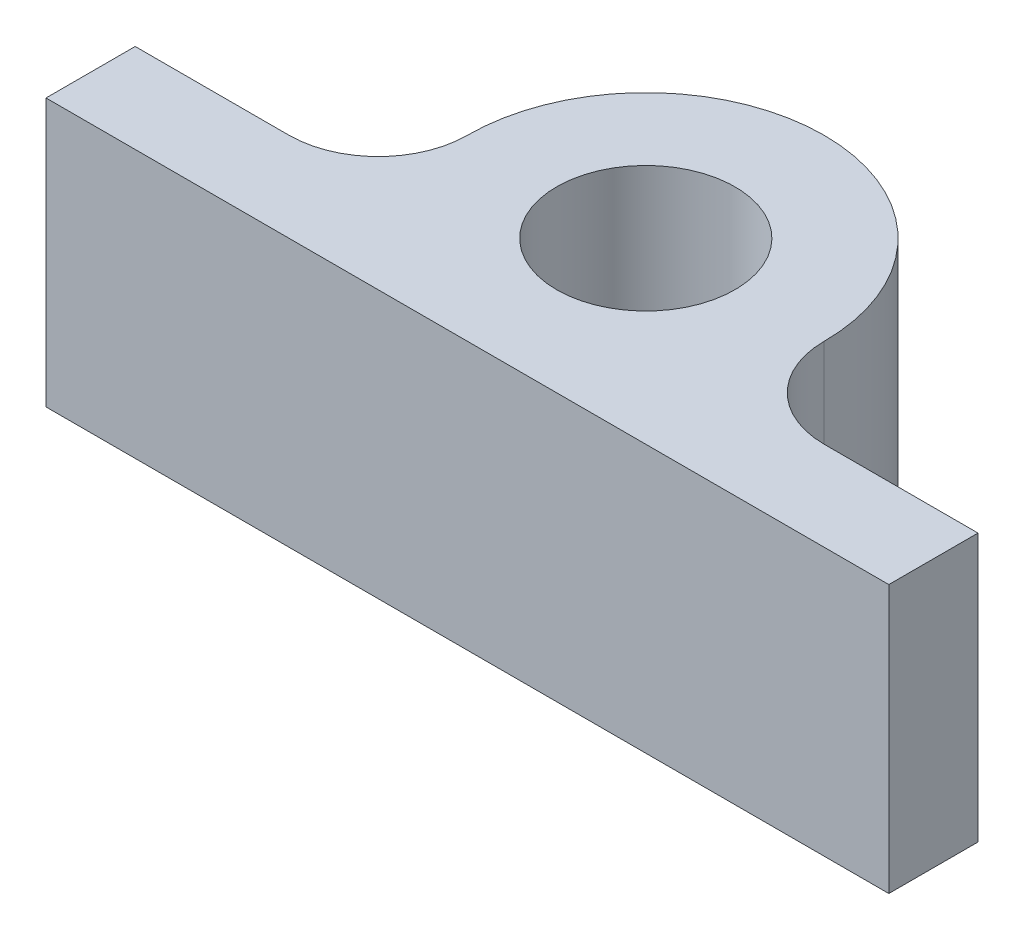
from build123d import *

# Parameters (mm, degrees)
SKETCH1_R           = 12.7
BOSS_EXTRUDE1_DEPTH = 38.1


with BuildPart() as part:
    # Sketch1 → Boss-Extrude1 (new body)
    with BuildSketch(Plane(origin=(0, 0, 0), x_dir=(1, 0, 0), z_dir=(0, 1, 0))):
        with BuildLine():
            ThreePointArc((25.4, 0), (29.119743879, -8.980256121), (38.1, -12.7))
            Line((38.1, -12.7), (60, -12.7))
            Line((60, -12.7), (60, -25.4))
            Line((60, -25.4), (-60, -25.4))
            Line((-60, -25.4), (-60, -12.7))
            Line((-60, -12.7), (-38.1, -12.7))
            ThreePointArc((-38.1, -12.7), (-29.119743879, -8.980256121), (-25.4, 0))
            ThreePointArc((-25.4, 0), (0, 25.4), (25.4, 0))
        make_face()
        Circle(SKETCH1_R, mode=Mode.SUBTRACT)
    extrude(amount=BOSS_EXTRUDE1_DEPTH)


solid = part.part
